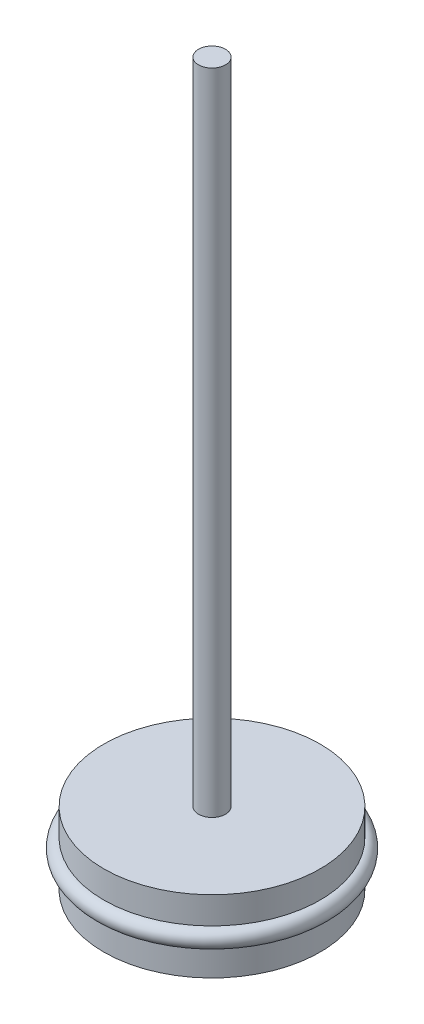
from build123d import *

# Parameters (mm, degrees)
SKETCH1_R           = 12
SKETCH1_R_2         = 1.5
BOSS_EXTRUDE1_DEPTH = 3
SKETCH3_R           = 1
BOSS_EXTRUDE2_START = 5
SKETCH1_2_R         = 12
SKETCH1_2_R_2       = 1.5
BOSS_EXTRUDE2_DEPTH = 3
SKETCH1_3_R         = 1.5
BOSS_EXTRUDE3_DEPTH = 80


with BuildPart() as part:
    # Sketch1 → Boss-Extrude1 (new body)
    with BuildSketch(Plane(origin=(0, 0, 0), x_dir=(1, 0, 0), z_dir=(0, 1, 0))):
        Circle(SKETCH1_R)
        Circle(SKETCH1_R_2, mode=Mode.SUBTRACT)
    extrude(amount=BOSS_EXTRUDE1_DEPTH)



with BuildPart() as body_2:
    # Sketch3 → Revolve1 (revolve)
    with BuildSketch(Plane.XY):
        with Locations((-12, 4)):
            Circle(SKETCH3_R)
    revolve(axis=Axis((0, 3, 0), (0, 1, 0)))


with BuildPart() as body_3:
    # Sketch1_2 → Boss-Extrude2 (new body)
    with BuildSketch(Plane(origin=(0, 0, 0), x_dir=(1, 0, 0), z_dir=(0, 1, 0)).offset(BOSS_EXTRUDE2_START)):
        Circle(SKETCH1_2_R)
        Circle(SKETCH1_2_R_2, mode=Mode.SUBTRACT)
    extrude(amount=BOSS_EXTRUDE2_DEPTH)


with BuildPart() as part_1:
    add(part.part)

    add(body_3.part)  # Boss-Extrude3 merges body 3
    # Sketch1_3 → Boss-Extrude3 (add)
    with BuildSketch(Plane(origin=(0, 0, 0), x_dir=(1, 0, 0), z_dir=(0, 1, 0))):
        Circle(SKETCH1_3_R)
    extrude(amount=BOSS_EXTRUDE3_DEPTH)


solid = Compound([body_2.part, part_1.part])
